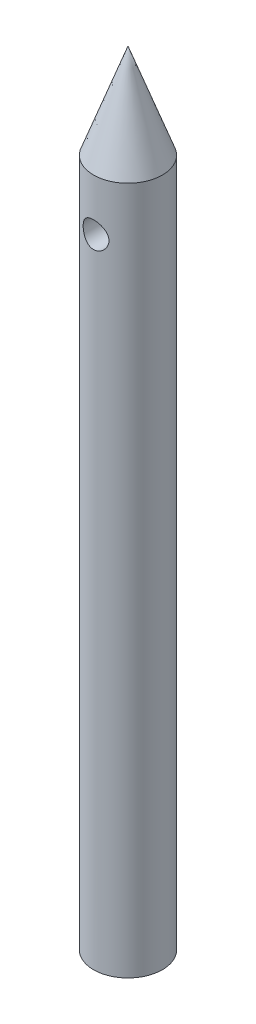
from build123d import *

# Parameters (mm, degrees)
SKETCH1_R           = 2
BOSS_EXTRUDE1_DEPTH = 40
SKETCH21_W          = 0.75
SKETCH21_H          = 4


with BuildPart() as part:
    # Sketch1 → Boss-Extrude1 (new body)
    with BuildSketch(Plane(origin=(0, 0, 0), x_dir=(1, 0, 0), z_dir=(0, 1, 0))):
        with Locations(Location((0, 0, 0), (0, 0, 270))):
            Circle(SKETCH1_R)
    extrude(amount=BOSS_EXTRUDE1_DEPTH)

    # Sketch21 → Ø1.5mm Dowel Hole4 (revolve, cut)
    with BuildSketch(Plane(origin=(0, 37, 2), x_dir=(0, -1, 0), z_dir=(1, 0, 0))):
        with Locations((0.375, 2)):
            Rectangle(SKETCH21_W, SKETCH21_H)
    revolve(axis=Axis((0, 37, 8.35), (0, 0, -1)), mode=Mode.SUBTRACT)


with BuildPart() as body_2:
    # Boss-Extrude2 cone 1 section (through the dimple's axis) → Boss-Extrude2 (revolve)
    with BuildSketch(Plane(origin=(0, 40, 0), x_dir=(0, 0, -1), z_dir=(1, 0, 0))):
        Polygon((0, 0), (2, 0), (0, 5.494954839), align=None)
    revolve(axis=Axis((0, 40, 0), (0, 1, 0)))


solid = Compound([part.part, body_2.part])
